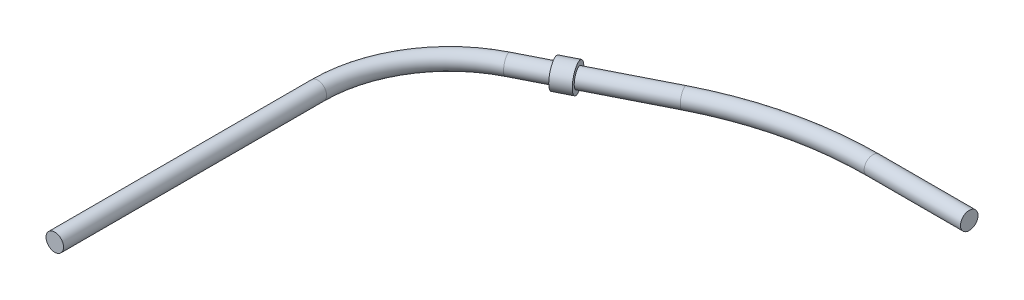
from build123d import *

# Parameters (mm, degrees)
ESQUISSE2_R        = 1
ESQUISSE3_R        = 1.5
ESQUISSE3_R_2      = 1
EXTRU_MINCE1_DEPTH = 1


with BuildPart() as part:
    # Balayage1: sweep along a path in Esquisse1
    with BuildLine(Plane(origin=(0, 0, 0), x_dir=(1, 0, 0), z_dir=(0, 1, 0))) as balayage1_path:
        Line((0, 0), (0, 30))
        ThreePointArc((0, 30), (2.22403872, 37.8596955), (8.236641781, 43.388688719))
        Line((8.236641781, 43.388688719), (21.6253305, 50.152046937))
        ThreePointArc((21.6253305, 50.152046937), (30.076611959, 53.244881504), (39.014580281, 54.29488448))
        Line((39.014580281, 54.29488448), (50, 54.29488448))
    # Esquisse2 → Balayage1 (sweep)
    with BuildSketch(Plane.XY):
        Circle(ESQUISSE2_R)
    sweep(path=balayage1_path.line)

    # Esquisse3 → Extru.-Mince1 (add, symmetric)
    with BuildSketch(Plane(origin=(28.487028331, 0, -14.390354518), x_dir=(0.450890548, 0, 0.892579248), z_dir=(-0.892579248, 0, 0.450890548))):
        with Locations((-35.014019219, 0)):
            Circle(ESQUISSE3_R)
        with Locations((-35.014019219, 0)):
            Circle(ESQUISSE3_R_2, mode=Mode.SUBTRACT)
    extrude(amount=EXTRU_MINCE1_DEPTH, both=True)


solid = part.part
